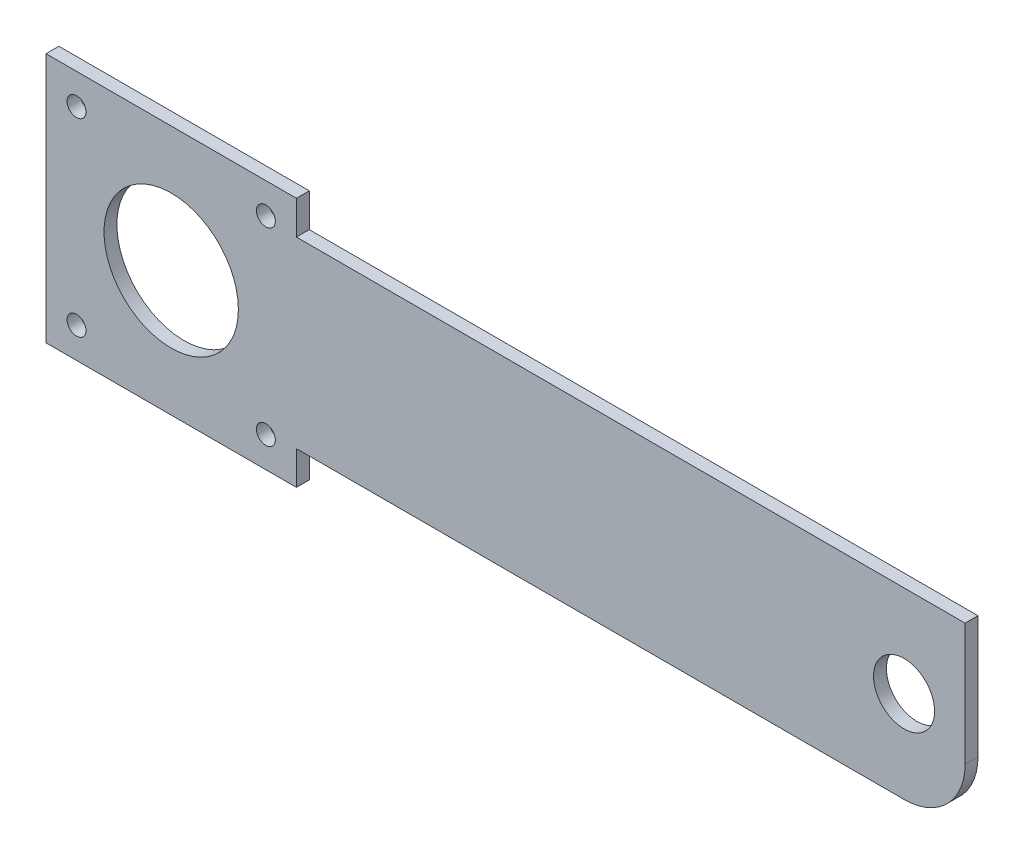
from build123d import *

# Parameters (mm, degrees)
CROQUIS1_R              = 1.55
SALIENTE_EXTRUIR1_DEPTH = 2.11
CROQUIS5_R              = 11
CORTAR_EXTRUIR1_DEPTH   = 2.11
CROQUIS6_R              = 5
CORTAR_EXTRUIR2_DEPTH   = 2.11
REDONDEO1_R             = 10


with BuildPart() as part:
    # Croquis1 → Saliente-Extruir1 (new body)
    with BuildSketch(Plane.XY):
        Polygon((158.208826457, -21.405767977), (158.208826457, 8.594232023), (48.708826457, 8.594232023), (48.708826457, 14.094232023), (7.708826457, 14.094232023), (7.708826457, -26.905767977), (48.708826457, -26.905767977), (48.708826457, -21.405767977), align=None)
        with Locations((12.708826457, -21.905767977)):
            Circle(CROQUIS1_R, mode=Mode.SUBTRACT)
        with Locations((12.708826457, 9.094232023)):
            Circle(CROQUIS1_R, mode=Mode.SUBTRACT)
        with Locations((43.708826457, 9.094232023)):
            Circle(CROQUIS1_R, mode=Mode.SUBTRACT)
        with Locations((43.708826457, -21.905767977)):
            Circle(CROQUIS1_R, mode=Mode.SUBTRACT)
    extrude(amount=SALIENTE_EXTRUIR1_DEPTH)

    # Croquis5 → Cortar-Extruir1 (cut)
    with BuildSketch(Plane.XY.offset(2.11)):
        with Locations((28.208826457, -6.405767977)):
            Circle(CROQUIS5_R)
    extrude(amount=-CORTAR_EXTRUIR1_DEPTH, mode=Mode.SUBTRACT)

    # Croquis6 → Cortar-Extruir2 (cut)
    with BuildSketch(Plane.XY.offset(2.11)):
        with Locations((148.208826457, -6.405767977)):
            Circle(CROQUIS6_R)
    extrude(amount=-CORTAR_EXTRUIR2_DEPTH, mode=Mode.SUBTRACT)

    # Redondeo1
    redondeo1_edges = [part.edges().sort_by_distance(p)[0] for p in [
        (158.208826457, -21.405767977, 1.055),
    ]]
    fillet(redondeo1_edges, radius=REDONDEO1_R)


solid = part.part
